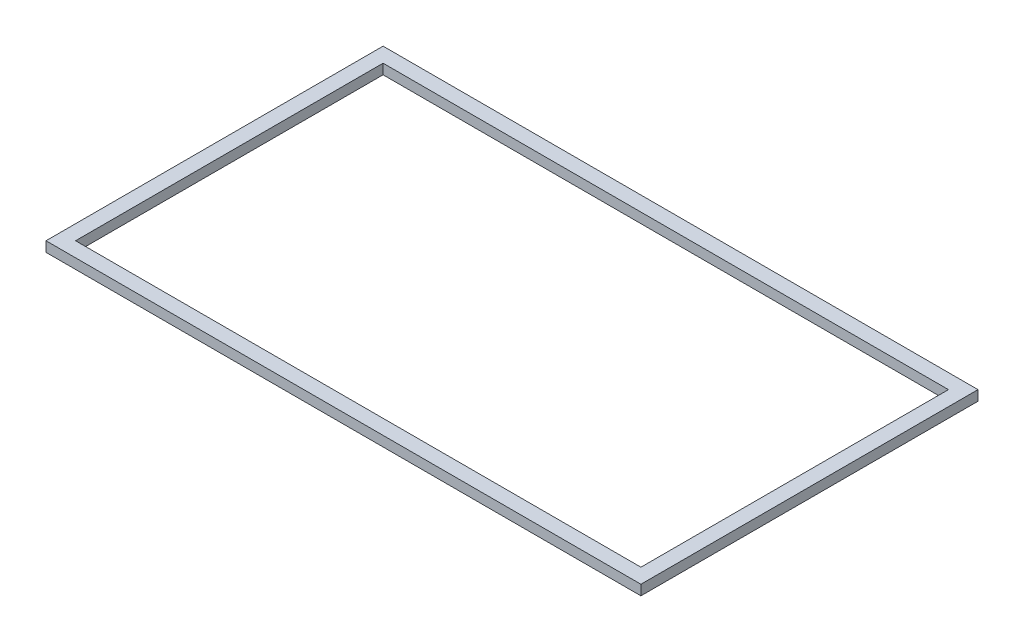
from build123d import *

# Parameters (mm, degrees)
SKIZZE2_W                       = 88.6
SKIZZE2_H                       = 50.2
SKIZZE2_W_2                     = 84.2
SKIZZE2_H_2                     = 45.8
AUFSATZ_LINEAR_AUSTRAGEN1_DEPTH = 1.5


with BuildPart() as part:
    # Skizze2 → Aufsatz-Linear austragen1 (new body)
    with BuildSketch(Plane(origin=(0, 0, 0), x_dir=(1, 0, 0), z_dir=(0, 1, 0))):
        Rectangle(SKIZZE2_W, SKIZZE2_H)
        Rectangle(SKIZZE2_W_2, SKIZZE2_H_2, mode=Mode.SUBTRACT)
    extrude(amount=AUFSATZ_LINEAR_AUSTRAGEN1_DEPTH)


solid = part.part
